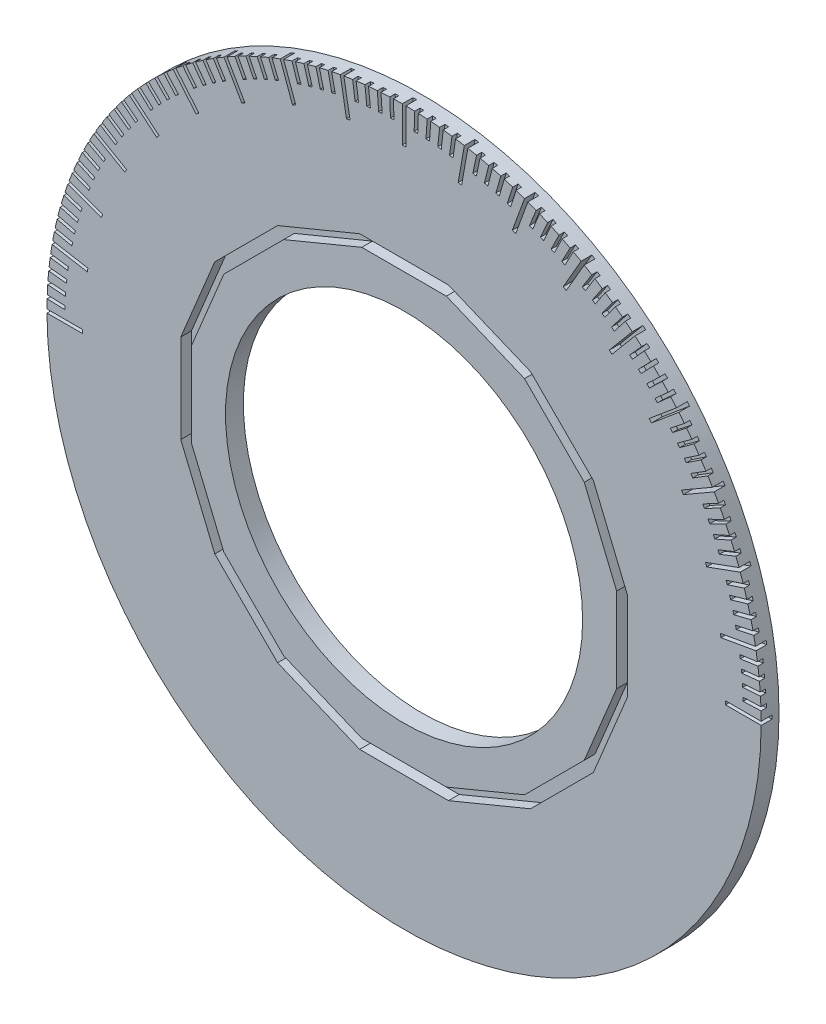
from build123d import *

# Parameters (mm, degrees)
SKETCH_1_R               = 40
EXTRUDE_1_DEPTH          = 2
CUT_EXTRUDE_1_DEPTH      = 1.2
SKETCH_7_R               = 20
CUT_EXTRUDE_8_DEPTH      = 22
SKETCH_8_W               = 2
SKETCH_8_H               = 0.4
CUT_EXTRUDE_10_DEPTH     = 0.6
PATTERN_CIRCULAR_1_COUNT = 91
PATTERN_CIRCULAR_1_ANGLE = 180
SKETCH_10_W              = 4
SKETCH_10_H              = 0.4
CUT_EXTRUDE_11_DEPTH     = 1.2
PATTERN_CIRCULAR_2_COUNT = 19
PATTERN_CIRCULAR_2_ANGLE = 180


with BuildPart() as part:
    # 스케치1 → 보스-돌출1 (new body)
    with BuildSketch(Plane.XY):
        Circle(SKETCH_1_R)
    extrude(amount=EXTRUDE_1_DEPTH)

    # 스케치2 → 컷-돌출1 (cut)
    with BuildSketch(Plane.XY.offset(2)):
        Polygon((21.202475114, -14.167040942), (25.01002465, -4.974803211), (25.01002465, 4.974803211), (21.202475114, 14.167040942), (14.167040942, 21.202475114), (4.974803211, 25.01002465), (-4.974803211, 25.01002465), (-14.167040942, 21.202475114), (-21.202475114, 14.167040942), (-25.01002465, 4.974803211), (-25.01002465, -4.974803211), (-21.202475114, -14.167040942), (-14.167040942, -21.202475114), (-4.974803211, -25.01002465), (4.974803211, -25.01002465), (14.167040942, -21.202475114), align=None)
        Polygon((20.185164236, -13.487295545), (23.81002465, -4.736108371), (23.81002465, 4.736108371), (20.185164236, 13.487295545), (13.487295545, 20.185164236), (4.736108371, 23.81002465), (-4.736108371, 23.81002465), (-13.487295545, 20.185164236), (-20.185164236, 13.487295545), (-23.81002465, 4.736108371), (-23.81002465, -4.736108371), (-20.185164236, -13.487295545), (-13.487295545, -20.185164236), (-4.736108371, -23.81002465), (4.736108371, -23.81002465), (13.487295545, -20.185164236), align=None, mode=Mode.SUBTRACT)
    extrude(amount=-CUT_EXTRUDE_1_DEPTH, mode=Mode.SUBTRACT)

    # 스케치7 → 컷-돌출8 (cut)
    with BuildSketch(Plane.XY.offset(2)):
        Circle(SKETCH_7_R)
    extrude(amount=-CUT_EXTRUDE_8_DEPTH, mode=Mode.SUBTRACT)

    # 스케치8 → 컷-돌출10 (cut)
    with BuildSketch(Plane.XY.offset(2)):
        with Locations((-39, 0)):
            Rectangle(SKETCH_8_W, SKETCH_8_H)
    cut_extrude_10 = extrude(amount=-CUT_EXTRUDE_10_DEPTH, mode=Mode.SUBTRACT)

    # 원형 패턴1: 컷-돌출10 ×91 about axis
    pattern_circular_1_axis = Axis((0, 0, 0), (0, 0, -1))
    for i in range(1, PATTERN_CIRCULAR_1_COUNT):
        add(cut_extrude_10.rotate(pattern_circular_1_axis, i * PATTERN_CIRCULAR_1_ANGLE / (PATTERN_CIRCULAR_1_COUNT - 1)), mode=Mode.SUBTRACT)

    # 스케치10 → 컷-돌출11 (cut)
    with BuildSketch(Plane.XY.offset(2)):
        with Locations((-38, 0)):
            Rectangle(SKETCH_10_W, SKETCH_10_H)
    cut_extrude_11 = extrude(amount=-CUT_EXTRUDE_11_DEPTH, mode=Mode.SUBTRACT)

    # 원형 패턴2: 컷-돌출11 ×19 about axis
    pattern_circular_2_axis = Axis((0, 0, 0), (0, 0, -1))
    for i in range(1, PATTERN_CIRCULAR_2_COUNT):
        add(cut_extrude_11.rotate(pattern_circular_2_axis, i * PATTERN_CIRCULAR_2_ANGLE / (PATTERN_CIRCULAR_2_COUNT - 1)), mode=Mode.SUBTRACT)


solid = part.part
